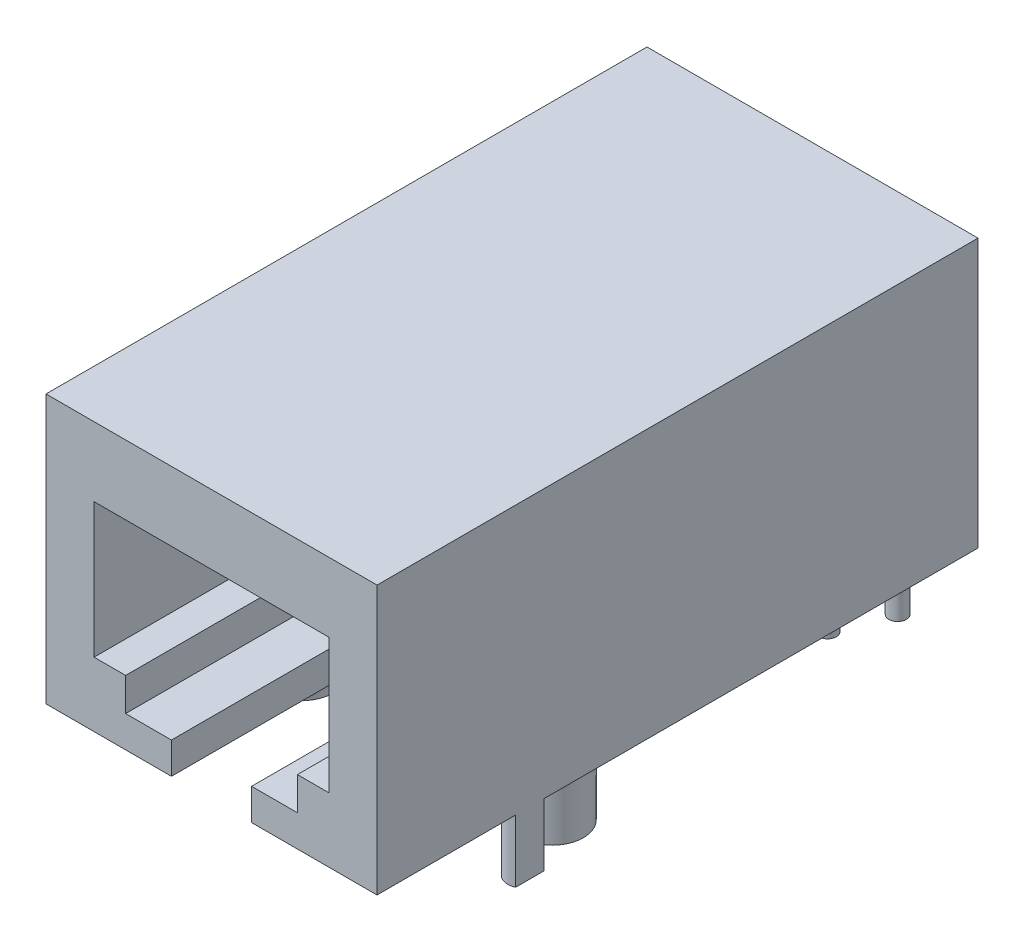
from build123d import *

# Parameters (mm, degrees)
SKETCH1_W           = 16.7894
SKETCH1_H           = 30.48
BOSS_EXTRUDE1_DEPTH = 13.6144
CUT_EXTRUDE1_DEPTH  = 17.78
SKETCH8_R           = 0.7874
SKETCH8_R_2         = 1.5875
SKETCH8_R_3         = 0.4445
BOSS_EXTRUDE3_DEPTH = 3.175
SKETCH9_W           = 0.569976
SKETCH9_H           = 6.35
BOSS_EXTRUDE4_DEPTH = 1.27
SKETCH10_W          = 4.064
SKETCH10_H          = 5.08
CUT_EXTRUDE2_DEPTH  = 1.27
SKETCH11_W          = 0.325641026
SKETCH11_H          = 1.628205128
BOSS_EXTRUDE5_DEPTH = 1.27
SKETCH12_W          = 0.904639056
SKETCH12_H          = 1.429638724
CUT_EXTRUDE3_DEPTH  = 25.4
SKETCH13_W          = 1.267919009
SKETCH13_H          = 1.429638724
CUT_EXTRUDE4_DEPTH  = 25.4
SKETCH14_R          = 0.635
CUT_EXTRUDE5_DEPTH  = 2.54
SKETCH15_R          = 0.635
CUT_EXTRUDE6_DEPTH  = 2.54


with BuildPart() as part:
    # Sketch1 → Boss-Extrude1 (new body)
    with BuildSketch(Plane(origin=(0, 0, 0), x_dir=(1, 0, 0), z_dir=(0, 1, 0))):
        with Locations((8.3947, 15.24)):
            Rectangle(SKETCH1_W, SKETCH1_H)
    extrude(amount=BOSS_EXTRUDE1_DEPTH)

    # Sketch4 → Cut-Extrude1 (cut)
    with BuildSketch(Plane.XY):
        Polygon((2.4384, 10.103565671), (14.351, 10.103565671), (14.351, 3.270965671), (12.7508, 3.270965671), (12.7508, 1.594565671), (10.4267, 1.594565671), (10.4267, 0), (6.3627, 0), (6.3627, 1.594565671), (4.0386, 1.594565671), (4.0386, 3.270965671), (2.4384, 3.270965671), align=None)
    extrude(amount=-CUT_EXTRUDE1_DEPTH, mode=Mode.SUBTRACT)

    # Sketch8 → Boss-Extrude3 (add)
    with BuildSketch(Plane.XZ):
        with Locations((0.3302, -7.747)):
            Circle(SKETCH8_R)
        with Locations((16.4592, -7.747)):
            Circle(SKETCH8_R)
        with Locations((2.0447, -10.922)):
            Circle(SKETCH8_R_2)
        with Locations((14.7447, -10.922)):
            Circle(SKETCH8_R_2)
        with Locations((6.3627, -28.702)):
            Circle(SKETCH8_R_3)
        with Locations((3.3147, -26.162)):
            Circle(SKETCH8_R_3)
        with Locations((4.3307, -28.702)):
            Circle(SKETCH8_R_3)
        with Locations((5.3467, -26.162)):
            Circle(SKETCH8_R_3)
        with Locations((11.4427, -26.162)):
            Circle(SKETCH8_R_3)
        with Locations((13.4747, -26.162)):
            Circle(SKETCH8_R_3)
        with Locations((10.4267, -28.702)):
            Circle(SKETCH8_R_3)
        with Locations((12.4587, -28.702)):
            Circle(SKETCH8_R_3)
        with Locations((14.4907, -28.702)):
            Circle(SKETCH8_R_3)
    extrude(amount=BOSS_EXTRUDE3_DEPTH)

    # Sketch9 → Boss-Extrude4 (add)
    with BuildSketch(Plane.XZ.offset(-10.103565671)):
        with Locations((12.3952, -14.605)):
            Rectangle(SKETCH9_W, SKETCH9_H)
        with Locations((11.2522, -14.605)):
            Rectangle(SKETCH9_W, SKETCH9_H)
        with Locations((10.1092, -14.605)):
            Rectangle(SKETCH9_W, SKETCH9_H)
        with Locations((8.9662, -14.605)):
            Rectangle(SKETCH9_W, SKETCH9_H)
        with Locations((7.8232, -14.605)):
            Rectangle(SKETCH9_W, SKETCH9_H)
        with Locations((6.6802, -14.605)):
            Rectangle(SKETCH9_W, SKETCH9_H)
        with Locations((5.5372, -14.605)):
            Rectangle(SKETCH9_W, SKETCH9_H)
        with Locations((4.3942, -14.605)):
            Rectangle(SKETCH9_W, SKETCH9_H)
    extrude(amount=BOSS_EXTRUDE4_DEPTH)

    # Sketch10 → Cut-Extrude2 (cut)
    with BuildSketch(Plane.XY.offset(-17.78)):
        with Locations((8.3947, 2.54)):
            Rectangle(SKETCH10_W, SKETCH10_H)
    extrude(amount=-CUT_EXTRUDE2_DEPTH, mode=Mode.SUBTRACT)

    # Sketch11 → Boss-Extrude5 (add)
    with BuildSketch(Plane.XY.offset(-19.05)):
        with BuildLine():
            Line((7.041254487, 4.676205128), (7.041254487, 4.072942408))
            add(Edge.make_bspline(
                [(7.041254487, 4.072942408), (7.055443206, 4.085416626), (7.083357049, 4.109957488), (7.128604215, 4.141414997), (7.175227593, 4.168396481), (7.223650029, 4.190480675), (7.274029318, 4.207255347), (7.325872909, 4.219929789), (7.379642188, 4.226823378), (7.415957142, 4.227902998), (7.434313381, 4.228448718)],
                knots=[0, 0, 0, 0, 5.6639e-05, 0.000111427, 0.000164992, 0.000218077, 0.000270772, 0.000324071, 0.000377952, 0.000433027, 0.000433027, 0.000433027, 0.000433027], degree=3))
            add(Edge.make_bspline(
                [(7.434313381, 4.228448718), (7.454268464, 4.228000278), (7.493495435, 4.227118752), (7.55114606, 4.2189513), (7.606459059, 4.205449704), (7.659699449, 4.187254621), (7.710320006, 4.162922864), (7.75890517, 4.133966179), (7.805188905, 4.099477017), (7.848308199, 4.059755812), (7.888419964, 4.016662594), (7.92327484, 3.969620476), (7.952562961, 3.919550158), (7.976603801, 3.866575922), (7.995483061, 3.810668061), (8.008685551, 3.751619876), (8.016861848, 3.689654209), (8.017733489, 3.64736642), (8.018177564, 3.625822015)],
                knots=[0, 0, 0, 0, 5.984e-05, 0.000117631, 0.000174244, 0.000230464, 0.000286082, 0.00034242, 0.000399917, 0.000458893, 0.000518085, 0.000576281, 0.000634149, 0.000691787, 0.000750516, 0.000810845, 0.000873049, 0.000937655, 0.000937655, 0.000937655, 0.000937655], degree=3))
            add(Edge.make_bspline(
                [(8.018177564, 3.625822015), (8.017619252, 3.605017631), (8.01651807, 3.563984256), (8.008063637, 3.503807615), (7.994469918, 3.446255506), (7.975221576, 3.391342842), (7.950353317, 3.338950033), (7.919625625, 3.289335139), (7.88376867, 3.242130521), (7.842691868, 3.198520001), (7.798088167, 3.158653804), (7.751068565, 3.123335365), (7.701464628, 3.094204801), (7.650324614, 3.069640094), (7.596898147, 3.050788015), (7.541343638, 3.037641037), (7.483882024, 3.028884706), (7.444840277, 3.028063062), (7.425091126, 3.027647436)],
                knots=[0, 0, 0, 0, 6.2395e-05, 0.000123065, 0.000181917, 0.000239547, 0.000297299, 0.000355549, 0.000414319, 0.000474842, 0.000534976, 0.000593617, 0.000650937, 0.000707267, 0.000763591, 0.000820514, 0.00087835, 0.000937554, 0.000937554, 0.000937554, 0.000937554], degree=3))
            add(Edge.make_bspline(
                [(7.425091126, 3.027647436), (7.407477038, 3.02809365), (7.372768585, 3.028972912), (7.321644473, 3.035381274), (7.272430436, 3.046355333), (7.224548826, 3.061169196), (7.177882845, 3.081678728), (7.131711287, 3.107241141), (7.085658226, 3.138248355), (7.056330433, 3.162236439), (7.041254487, 3.174567508)],
                knots=[0, 0, 0, 0, 5.2836e-05, 0.000104114, 0.000154266, 0.000203951, 0.000254227, 0.000306891, 0.000362104, 0.000420511, 0.000420511, 0.000420511, 0.000420511], degree=3))
            Line((7.041254487, 3.174567508), (7.041254487, 3.048))
            Line((7.041254487, 3.048), (6.715613462, 3.048))
            Line((6.715613462, 3.048), (6.715613462, 4.676205128))
            Line((6.715613462, 4.676205128), (7.041254487, 4.676205128))
        make_face()
        with BuildLine():
            add(Edge.make_bspline(
                [(7.358309275, 3.963865385), (7.346427349, 3.963512162), (7.323121844, 3.962819342), (7.288795158, 3.958774276), (7.25617485, 3.951355514), (7.224875289, 3.941542603), (7.195342805, 3.928510978), (7.167423544, 3.912359657), (7.140940695, 3.893601071), (7.116305128, 3.872006817), (7.09368945, 3.848361697), (7.074207742, 3.822496672), (7.058018569, 3.794825294), (7.04399699, 3.765741561), (7.033637975, 3.734507865), (7.026412805, 3.701561204), (7.021820909, 3.666973296), (7.021212982, 3.643327205), (7.020901923, 3.631228165)],
                knots=[0, 0, 0, 0, 3.5652e-05, 6.993e-05, 0.000103491, 0.000135875, 0.000168196, 0.000200107, 0.000232491, 0.000265398, 0.000298241, 0.000330487, 0.000362283, 0.00039429, 0.000427174, 0.000460736, 0.000495368, 0.000531656, 0.000531656, 0.000531656, 0.000531656], degree=3))
            add(Edge.make_bspline(
                [(7.020901923, 3.631228165), (7.021217804, 3.618917634), (7.021838063, 3.594744885), (7.026395413, 3.559416893), (7.033567683, 3.525811916), (7.044141411, 3.494030747), (7.057933244, 3.464220032), (7.074105036, 3.435874409), (7.093793472, 3.409648072), (7.116177977, 3.385362558), (7.140957967, 3.363487597), (7.167329433, 3.344354556), (7.195336832, 3.328183172), (7.225002194, 3.315368063), (7.256039736, 3.304541069), (7.288814555, 3.297381043), (7.323116723, 3.293261191), (7.346425619, 3.292578717), (7.358309275, 3.292230769)],
                knots=[0, 0, 0, 0, 3.6923e-05, 7.2502e-05, 0.000106685, 0.00013987, 0.000172742, 0.000205087, 0.000237588, 0.000270895, 0.000304013, 0.000336582, 0.000368492, 0.000400814, 0.000433397, 0.000466958, 0.000501235, 0.000536888, 0.000536888, 0.000536888, 0.000536888], degree=3))
            add(Edge.make_bspline(
                [(7.358309275, 3.292230769), (7.369879233, 3.292543288), (7.392576289, 3.293156365), (7.425886603, 3.297778039), (7.457894948, 3.304973741), (7.488455961, 3.315528241), (7.517592899, 3.329033684), (7.545464398, 3.345191477), (7.571547305, 3.364893446), (7.596353228, 3.386922801), (7.618580717, 3.411630923), (7.63870557, 3.437751336), (7.655136672, 3.465981617), (7.669004216, 3.495609817), (7.679403095, 3.52703132), (7.687163911, 3.559995996), (7.69155441, 3.594644857), (7.692206031, 3.618284106), (7.692536538, 3.630274139)],
                knots=[0, 0, 0, 0, 3.4699e-05, 6.8071e-05, 0.000100702, 0.000132984, 0.000164856, 0.000196926, 0.000229427, 0.000262756, 0.000296298, 0.00032899, 0.000361495, 0.000394078, 0.000426962, 0.000460595, 0.000495542, 0.000531513, 0.000531513, 0.000531513, 0.000531513], degree=3))
            add(Edge.make_bspline(
                [(7.692536538, 3.630274139), (7.692213944, 3.642159924), (7.691577985, 3.6655914), (7.68707873, 3.699877051), (7.679738689, 3.732554522), (7.669685912, 3.763567427), (7.656090088, 3.792834761), (7.639561441, 3.820351928), (7.620337937, 3.846486364), (7.598106338, 3.870407881), (7.57377882, 3.892303561), (7.547566383, 3.911472167), (7.519914316, 3.927784956), (7.490511241, 3.940875225), (7.459803182, 3.95142553), (7.427295485, 3.95880366), (7.39328512, 3.962804411), (7.370085381, 3.963508163), (7.358309275, 3.963865385)],
                knots=[0, 0, 0, 0, 3.5652e-05, 7.0285e-05, 0.000103536, 0.000136018, 0.000167891, 0.000200123, 0.000232178, 0.000265037, 0.000297916, 0.000330228, 0.000362298, 0.000394039, 0.000426622, 0.000459563, 0.00049384, 0.000529175, 0.000529175, 0.000529175, 0.000529175], degree=3))
        make_face(mode=Mode.SUBTRACT)
        with BuildLine():
            Line((9.563700401, 3.556814103), (8.547344231, 3.556814103))
            add(Edge.make_bspline(
                [(8.547344231, 3.556814103), (8.549401179, 3.546175775), (8.553451848, 3.525226118), (8.562369058, 3.494840177), (8.57390345, 3.466321706), (8.587246857, 3.43925452), (8.603232526, 3.413986121), (8.621822724, 3.390588815), (8.642124312, 3.36832231), (8.665164492, 3.34846842), (8.68982059, 3.330294472), (8.71642308, 3.314558229), (8.74486296, 3.301611279), (8.774769779, 3.290848259), (8.806189971, 3.282087781), (8.839404226, 3.276130855), (8.874289271, 3.272670801), (8.898100181, 3.272145151), (8.910192288, 3.271878205)],
                knots=[0, 0, 0, 0, 3.2495e-05, 6.399e-05, 9.4816e-05, 0.000124682, 0.000154413, 0.000184313, 0.000214241, 0.000244665, 0.000275387, 0.000306039, 0.0003372, 0.000368988, 0.000401314, 0.000434935, 0.00047009, 0.000506366, 0.000506366, 0.000506366, 0.000506366], degree=3))
            add(Edge.make_bspline(
                [(8.910192288, 3.271878205), (8.924843104, 3.27221672), (8.953624088, 3.272881721), (8.995940544, 3.278978537), (9.036848646, 3.287901972), (9.075957344, 3.301456214), (9.113574596, 3.318427128), (9.149563056, 3.339199016), (9.184177548, 3.363688799), (9.205378688, 3.382749546), (9.216116767, 3.392403546)],
                knots=[0, 0, 0, 0, 4.3927e-05, 8.6292e-05, 0.000128029, 0.000169362, 0.000210208, 0.000251664, 0.000293844, 0.000337133, 0.000337133, 0.000337133, 0.000337133], degree=3))
            Line((9.216116767, 3.392403546), (9.483562179, 3.278874399))
            add(Edge.make_bspline(
                [(9.483562179, 3.278874399), (9.475221702, 3.268471445), (9.458621062, 3.247765712), (9.431431537, 3.219072417), (9.40355022, 3.191848864), (9.374217608, 3.166989631), (9.343531852, 3.144397633), (9.311778773, 3.123611891), (9.278528378, 3.105219156), (9.244206071, 3.088571193), (9.208355565, 3.074244535), (9.170933987, 3.061883751), (9.132040788, 3.051004302), (9.091336394, 3.042468176), (9.049191662, 3.035849442), (9.005365426, 3.031084267), (8.959947475, 3.028176701), (8.92906517, 3.027825764), (8.913372376, 3.027647436)],
                knots=[0, 0, 0, 0, 3.9984e-05, 7.9584e-05, 0.000118492, 0.000156848, 0.000194819, 0.000232748, 0.000270616, 0.000308735, 0.000347119, 0.000386339, 0.000426921, 0.000468211, 0.00051103, 0.000554857, 0.000600423, 0.000647498, 0.000647498, 0.000647498, 0.000647498], degree=3))
            add(Edge.make_bspline(
                [(8.913372376, 3.027647436), (8.889182215, 3.028097876), (8.841725591, 3.028981557), (8.772341722, 3.037027224), (8.706413188, 3.05045259), (8.643836291, 3.068771172), (8.584666737, 3.092668553), (8.529108968, 3.122222826), (8.476628661, 3.156453131), (8.428645358, 3.196338768), (8.384775591, 3.239477396), (8.346661743, 3.286232124), (8.314524861, 3.335672368), (8.287703607, 3.387525479), (8.267337962, 3.442351929), (8.252808861, 3.499817933), (8.243542129, 3.559906217), (8.242556439, 3.600877178), (8.242055769, 3.621687901)],
                knots=[0, 0, 0, 0, 7.2551e-05, 0.000142331, 0.000209188, 0.00027419, 0.000337672, 0.000400264, 0.000462711, 0.000525294, 0.000587133, 0.000647031, 0.000705863, 0.000763749, 0.000821812, 0.000880893, 0.000941338, 0.001003734, 0.001003734, 0.001003734, 0.001003734], degree=3))
            add(Edge.make_bspline(
                [(8.242055769, 3.621687901), (8.24255057, 3.643029693), (8.243524973, 3.685057661), (8.252846645, 3.746470692), (8.266933723, 3.805303607), (8.287584351, 3.861179286), (8.313506335, 3.914614238), (8.346176349, 3.964675762), (8.383755327, 4.012459027), (8.427215674, 4.056610323), (8.475021564, 4.096702521), (8.525968286, 4.132397871), (8.58029768, 4.161899676), (8.637379629, 4.186223715), (8.697357998, 4.205543919), (8.760507816, 4.218471147), (8.826414778, 4.227264541), (8.871365139, 4.228048741), (8.894291847, 4.228448718)],
                knots=[0, 0, 0, 0, 6.3984e-05, 0.000126002, 0.000185931, 0.000245188, 0.000304352, 0.000363718, 0.000424161, 0.000486452, 0.000549198, 0.000611125, 0.000672747, 0.000734296, 0.000797053, 0.00086142, 0.000927449, 0.000996186, 0.000996186, 0.000996186, 0.000996186], degree=3))
            add(Edge.make_bspline(
                [(8.894291847, 4.228448718), (8.918588675, 4.228008335), (8.966047295, 4.227148142), (9.035529145, 4.219014287), (9.101450812, 4.205643359), (9.164169397, 4.187517781), (9.222873791, 4.162836963), (9.278728866, 4.134129368), (9.330613357, 4.099114765), (9.378923978, 4.059473841), (9.422658654, 4.015586521), (9.460831743, 3.967814974), (9.493235984, 3.916710146), (9.519292869, 3.861955854), (9.539820048, 3.803982813), (9.554301071, 3.742573409), (9.563515954, 3.677724719), (9.564479838, 3.633274259), (9.564972436, 3.610557592)],
                knots=[0, 0, 0, 0, 7.2868e-05, 0.000142333, 0.000209502, 0.000274503, 0.000337812, 0.000400256, 0.000462613, 0.000525196, 0.000587485, 0.000648125, 0.000708296, 0.000768605, 0.000829657, 0.000892442, 0.000957609, 0.001025723, 0.001025723, 0.001025723, 0.001025723], degree=3))
            Line((9.564972436, 3.610557592), (9.563700401, 3.556814103))
        make_face()
        with BuildLine():
            add(Edge.make_bspline(
                [(9.23933141, 3.780692308), (9.233477061, 3.795253626), (9.221742533, 3.824440503), (9.194756538, 3.86403512), (9.159814952, 3.898772734), (9.118402986, 3.928965241), (9.071501909, 3.95367586), (9.020427127, 3.971617537), (8.965654731, 3.982337874), (8.927943587, 3.983580585), (8.908602244, 3.984217949)],
                knots=[0, 0, 0, 0, 4.698e-05, 9.4168e-05, 0.000142515, 0.000194163, 0.000247364, 0.000300972, 0.000356043, 0.000414026, 0.000414026, 0.000414026, 0.000414026], degree=3))
            add(Edge.make_bspline(
                [(8.908602244, 3.984217949), (8.887646963, 3.983595042), (8.846639185, 3.982376063), (8.787351793, 3.969571052), (8.731341779, 3.950489338), (8.69789559, 3.930552665), (8.681225942, 3.920616186)],
                knots=[0, 0, 0, 0, 6.2764e-05, 0.000122824, 0.000181266, 0.000239335, 0.000239335, 0.000239335, 0.000239335], degree=3))
            add(Edge.make_bspline(
                [(8.681225942, 3.920616186), (8.670870057, 3.913098794), (8.649013249, 3.897232821), (8.620337141, 3.865070153), (8.592522461, 3.825974875), (8.576288196, 3.796363214), (8.567696795, 3.780692308)],
                knots=[0, 0, 0, 0, 3.8295e-05, 8.0824e-05, 0.000128475, 0.00018204, 0.00018204, 0.00018204, 0.00018204], degree=3))
            Line((8.567696795, 3.780692308), (9.23933141, 3.780692308))
        make_face(mode=Mode.SUBTRACT)
        with Locations((9.951671154, 3.862102564)):
            Rectangle(SKETCH11_W, SKETCH11_H)
    extrude(amount=BOSS_EXTRUDE5_DEPTH)

    # Sketch12 → Cut-Extrude3 (cut)
    with BuildSketch(Plane(origin=(0, 0, 0), x_dir=(1, 0, 0), z_dir=(0, 1, 0))):
        with Locations((-0.452319528, 7.747)):
            Rectangle(SKETCH12_W, SKETCH12_H)
    extrude(amount=-CUT_EXTRUDE3_DEPTH, mode=Mode.SUBTRACT)

    # Sketch13 → Cut-Extrude4 (cut)
    with BuildSketch(Plane(origin=(0, 0, 0), x_dir=(1, 0, 0), z_dir=(0, 1, 0))):
        with Locations((17.423359504, 7.747)):
            Rectangle(SKETCH13_W, SKETCH13_H)
    extrude(amount=-CUT_EXTRUDE4_DEPTH, mode=Mode.SUBTRACT)

    # Sketch14 → Cut-Extrude5 (cut)
    with BuildSketch(Plane.XZ.offset(3.175)):
        with Locations((2.0447, -10.922)):
            Circle(SKETCH14_R)
    extrude(amount=-CUT_EXTRUDE5_DEPTH, mode=Mode.SUBTRACT)

    # Sketch15 → Cut-Extrude6 (cut)
    with BuildSketch(Plane.XZ.offset(3.175)):
        with Locations((14.7447, -10.922)):
            Circle(SKETCH15_R)
    extrude(amount=-CUT_EXTRUDE6_DEPTH, mode=Mode.SUBTRACT)


solid = part.part
